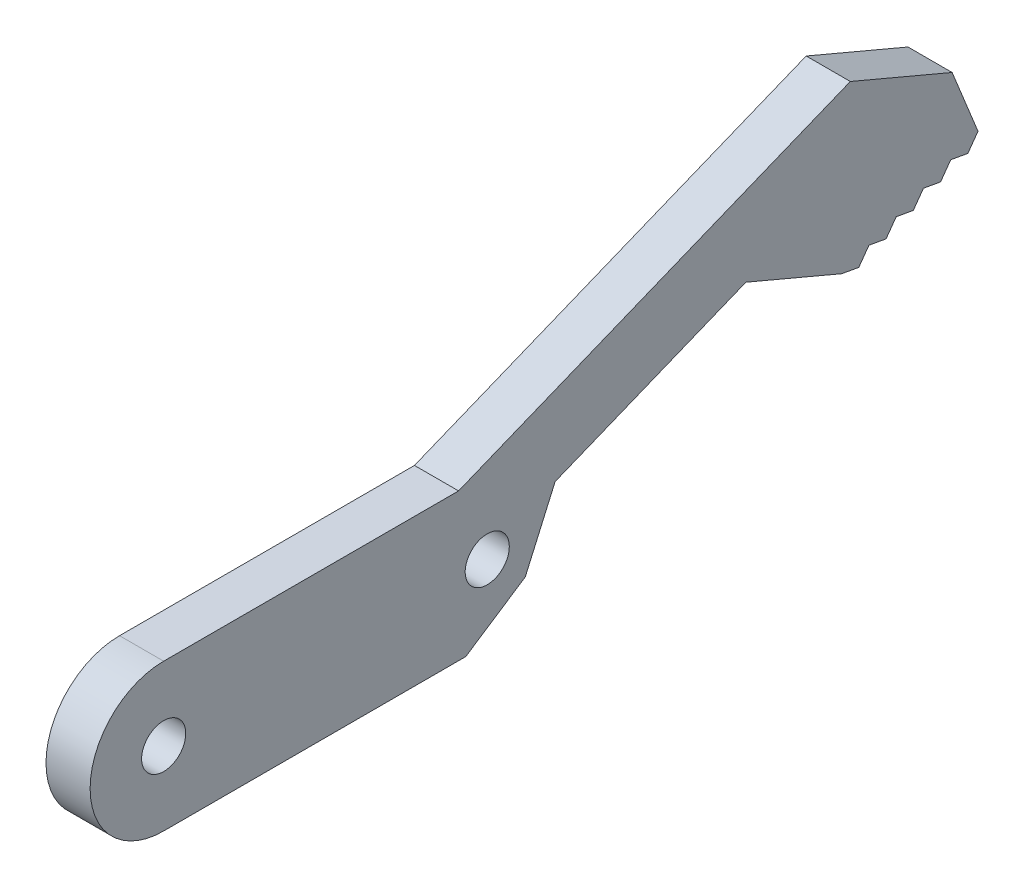
from build123d import *

# Parameters (mm, degrees)
SKETCH1_R           = 5
SKETCH1_R_2         = 1.5
BOSS_EXTRUDE1_DEPTH = 3
BOSS_EXTRUDE2_DEPTH = 3
CUT_EXTRUDE2_DEPTH  = 4
CUT_EXTRUDE3_DEPTH  = 10


with BuildPart() as part:
    # Sketch1 → Boss-Extrude1 (new body)
    with BuildSketch(Plane(origin=(0, 0, 0), x_dir=(0, 0, -1), z_dir=(1, 0, 0))):
        with Locations((5, 5)):
            Circle(SKETCH1_R)
        with Locations((5, 5)):
            Circle(SKETCH1_R_2, mode=Mode.SUBTRACT)
        with BuildLine():
            ThreePointArc((10, 5), (8.535533906, 1.464466094), (5, 0))
            Line((5, 0), (27, 0))
            ThreePointArc((27, 0), (22, 5), (27, 10))
            Line((27, 10), (5, 10))
            ThreePointArc((5, 10), (8.535533906, 8.535533906), (10, 5))
        make_face()
        with Locations((27, 5)):
            Circle(SKETCH1_R)
        with Locations((27, 5)):
            Circle(SKETCH1_R_2, mode=Mode.SUBTRACT)
    extrude(amount=BOSS_EXTRUDE1_DEPTH)

    # Sketch2 → Boss-Extrude2 (add)
    with BuildSketch(Plane(origin=(3, 0, 0), x_dir=(0, 0, -1), z_dir=(1, 0, 0))):
        with BuildLine():
            ThreePointArc((27, 10), (29.694507461, 9.21184396), (31.53953799, 7.095851816))
            Line((31.53953799, 7.095851816), (31.610157793, 7.262674791))
            Line((31.610157793, 7.262674791), (44.585599673, 12.519851602))
            Line((44.585599673, 12.519851602), (51.097249205, 9.763328363))
            Line((51.097249205, 9.763328363), (60.365421977, 13.518454657))
            Line((60.365421977, 13.518454657), (56.610295683, 22.786627428))
            Line((56.610295683, 22.786627428), (25.051124858, 10))
            Line((25.051124858, 10), (27, 10))
        make_face()
        Polygon((60.365421977, 13.518454657), (51.097249205, 9.763328363), (51.333822162, 9.179433479), (60.601994933, 12.934559772), align=None)
    extrude(amount=-BOSS_EXTRUDE2_DEPTH)

    # Sketch4 → Cut-Extrude2 (cut, through all)
    with BuildSketch(Plane(origin=(3, 0, 0), x_dir=(0, 0, -1), z_dir=(1, 0, 0))):
        Polygon((56.610295683, 22.786627428), (51.684261855, 20.790777803), (58.606145308, 17.8605936), align=None)
    extrude(amount=-CUT_EXTRUDE2_DEPTH, mode=Mode.SUBTRACT)

    # Sketch5 → Cut-Extrude3 (cut)
    with BuildSketch(Plane(origin=(3, 0, 0), x_dir=(0, 0, -1), z_dir=(1, 0, 0))):
        with BuildLine():
            ThreePointArc((27, 0), (31.21184396, 2.305492539), (31.53953799, 7.095851816))
            Line((31.53953799, 7.095851816), (29.583779735, 2.664986829))
            Line((29.583779735, 2.664986829), (25.539598719, 0))
            Line((25.539598719, 0), (27, 0))
        make_face()
        Polygon((52.260639439, 9.554946108), (51.097249205, 9.763328363), (51.333822162, 9.179433479), align=None)
        Polygon((52.95088376, 10.514353622), (52.260639439, 9.554946108), (54.114273993, 10.305971367), align=None)
        Polygon((54.804518314, 11.265378881), (54.114273993, 10.305971367), (55.967908548, 11.056996626), align=None)
        Polygon((56.658152868, 12.01640414), (55.967908548, 11.056996626), (57.821543102, 11.808021884), align=None)
        Polygon((58.511787422, 12.767429398), (57.821543102, 11.808021884), (59.675177656, 12.559047143), align=None)
        Polygon((60.365421977, 13.518454657), (59.675177656, 12.559047143), (60.601994933, 12.934559772), align=None)
    extrude(amount=-CUT_EXTRUDE3_DEPTH, mode=Mode.SUBTRACT)


solid = part.part
